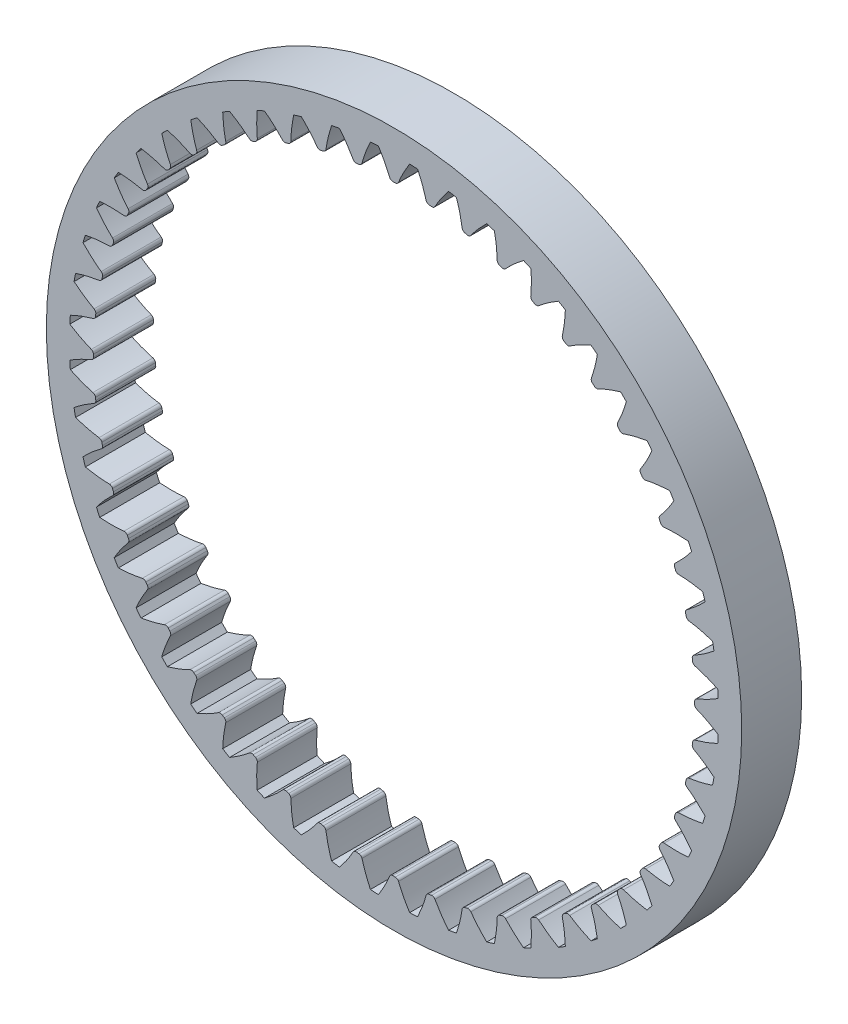
from build123d import *

# Parameters (mm, degrees)
SKETCH1_R               = 29
BOSS_EXTRUDE1_DEPTH     = 5
CUT_EXTRUDE1_DEPTH      = 6
CUT_EXTRUDE4_DEPTH      = 6.0000001
SKETCH3_R               = 25
CUT_EXTRUDE2_DEPTH      = 6.0000007
TOLERANCETOOTHCUT_DEPTH = 6.0000001
SKETCH8_R               = 25.07
TOLERANCEDID_DEPTH      = 6.0000001
CIRPATTERN1_COUNT       = 52


with BuildPart() as part:
    # Sketch1 → Boss-Extrude1 (new body)
    with BuildSketch(Plane.XY):
        Circle(SKETCH1_R)
    extrude(amount=BOSS_EXTRUDE1_DEPTH)

    # Sketch2 → Cut-Extrude1 (cut, through all)
    with BuildSketch(Plane.XY.offset(5)):
        with BuildLine():
            ThreePointArc((23.392853464, 2.834893097), (23.521011218, 1.422759062), (23.564001827, 0.005473364))
            add(Edge.make_bspline(
                [(23.564001827, 0.005473364), (23.569452708, 0.005539136), (23.584739427, 0.005923405), (23.613631002, 0.007438906), (23.660749085, 0.011032333), (23.720736108, 0.017257727), (23.798193272, 0.027194443), (23.889319268, 0.041330251), (23.989313256, 0.05940956), (24.097912346, 0.081822988), (24.206066118, 0.106608207), (24.313757985, 0.133587355), (24.420844889, 0.162495059), (24.550313362, 0.199910393), (24.705199064, 0.248107841), (24.885655098, 0.309290433), (25.089588699, 0.384394405), (25.296573432, 0.467032925), (25.49951497, 0.553352797), (25.703644763, 0.646303319), (25.900497494, 0.740300864), (26.103942442, 0.84378837), (26.291216414, 0.942291058), (26.499814884, 1.059103077), (26.667806924, 1.155257611), (26.840274008, 1.259949266), (26.924054804, 1.311694031), (26.966803552, 1.338471577)],
                knots=[0, 0, 0, 0, 0, 0.005376749, 0.015083688, 0.02853182, 0.04661014, 0.064854849, 0.092110526, 0.119476176, 0.146842496, 0.174208854, 0.201574956, 0.228941013, 0.256307345, 0.307035032, 0.361767352, 0.416499661, 0.471231937, 0.525964282, 0.580696616, 0.635428982, 0.690161387, 0.744893688, 0.799626082, 0.854358407, 0.909090914, 0.909090914, 0.909090914, 0.909090914, 0.909090914], degree=4))
            ThreePointArc((26.966803552, 1.338471577), (26.950739932, 1.630219428), (26.931520113, 1.921776365))
            add(Edge.make_bspline(
                [(23.392853464, 2.834893097), (23.39827253, 2.835484836), (23.41349411, 2.836945978), (23.442357707, 2.838924022), (23.489565386, 2.841036252), (23.549865424, 2.842086885), (23.627955576, 2.841559048), (23.720121044, 2.838510331), (23.821565183, 2.832615785), (23.932074104, 2.823455949), (24.042426842, 2.811887939), (24.15258549, 2.798086319), (24.262376049, 2.782297285), (24.395410472, 2.76076045), (24.554976443, 2.731583825), (24.741491496, 2.692598894), (24.952990974, 2.642623993), (25.168427529, 2.585537254), (25.380294105, 2.52430865), (25.59413951, 2.45664097), (25.800887114, 2.387056748), (26.01532276, 2.308846361), (26.213104481, 2.233635251), (26.434262166, 2.142818691), (26.612619504, 2.067614434), (26.796448293, 1.984474709), (26.885855375, 1.94320588), (26.931520113, 1.921776365)],
                knots=[0, 0, 0, 0, 0, 0.005376749, 0.015083688, 0.02853182, 0.04661014, 0.064854849, 0.092110526, 0.119476176, 0.146842496, 0.174208854, 0.201574956, 0.228941013, 0.256307345, 0.307035032, 0.361767352, 0.416499661, 0.471231937, 0.525964282, 0.580696616, 0.635428982, 0.690161387, 0.744893688, 0.799626082, 0.854358407, 0.909090914, 0.909090914, 0.909090914, 0.909090914, 0.909090914], degree=4))
        make_face()
    extrude(amount=-CUT_EXTRUDE1_DEPTH, mode=Mode.SUBTRACT)

    # Sketch5 → Cut-Extrude4 (cut, through all)
    with BuildSketch(Plane.XY.offset(5)):
        with BuildLine():
            Line((25.091558109, 2.605404787), (25.222659244, 0.438044664))
            ThreePointArc((25.222659244, 0.438044664), (25.060289868, 0.306558642), (24.999772798, 0.106583462))
            ThreePointArc((24.999772798, 0.106583462), (24.954388856, 1.509462436), (24.830343524, 2.907583272))
            ThreePointArc((24.830343524, 2.907583272), (24.914523701, 2.716360663), (25.091558109, 2.605404787))
        make_face()
    extrude(amount=-CUT_EXTRUDE4_DEPTH, mode=Mode.SUBTRACT)

    # Sketch3 → Cut-Extrude2 (cut, through all)
    with BuildSketch(Plane.XY.offset(5)):
        Circle(SKETCH3_R)
    extrude(amount=-CUT_EXTRUDE2_DEPTH, mode=Mode.SUBTRACT)

    # Sketch7 → ToleranceToothCut (cut, through all)
    with BuildSketch(Plane.XY.offset(5)):
        with BuildLine():
            ThreePointArc((24.899868486, 2.915724505), (25.024261144, 1.51368893), (25.069772162, 0.106881896))
            ThreePointArc((25.069772162, 0.106881896), (25.118378251, 0.267497922), (25.248790054, 0.37310484))
            add(Edge.make_bspline(
                [(27.038722282, 1.300921932), (26.974179666, 1.260492846), (26.908936657, 1.219980183), (26.793772456, 1.150205175), (26.714756133, 1.102772755), (26.643334443, 1.061099925), (26.538115612, 1.000543096), (26.465589104, 0.959675564), (26.314405679, 0.876234361), (26.240732064, 0.836785625), (26.09319084, 0.759926224), (26.017128282, 0.721150769), (25.865050101, 0.645972763), (25.789753884, 0.610003473), (25.560689891, 0.503706416), (25.405519661, 0.436170482), (25.248790054, 0.37310484)],
                knots=[0, 0, 0, 0, 0.125, 0.125, 0.1875, 0.25, 0.25, 0.375, 0.375, 0.5, 0.5, 0.625, 0.625, 0.75, 0.75, 1, 1, 1, 1], degree=3))
            ThreePointArc((27.038722282, 1.300921932), (27.02061222, 1.634445923), (26.998388365, 1.967721075))
            add(Edge.make_bspline(
                [(25.109670766, 2.673020848), (25.27285936, 2.629306692), (25.435038782, 2.580966875), (25.675245335, 2.503055457), (25.754328177, 2.476424379), (25.914359244, 2.420125505), (25.994541084, 2.390801095), (26.150270944, 2.332286215), (26.228162416, 2.302005478), (26.388301268, 2.237395803), (26.465225013, 2.205568346), (26.576975999, 2.158135773), (26.65290005, 2.125375718), (26.737057601, 2.087813499), (26.859792573, 2.03242874), (26.929443149, 2.000075636), (26.998388365, 1.967721075)],
                knots=[0, 0, 0, 0, 0.25, 0.25, 0.375, 0.375, 0.5, 0.5, 0.625, 0.625, 0.75, 0.75, 0.8125, 0.875, 0.875, 1, 1, 1, 1], degree=3))
            ThreePointArc((25.109670766, 2.673020848), (24.967480304, 2.762138367), (24.899868486, 2.915724505))
        make_face()
    tolerancetoothcut = extrude(amount=-TOLERANCETOOTHCUT_DEPTH, mode=Mode.SUBTRACT)

    # Sketch8 → TolerancedID (cut, through all)
    with BuildSketch(Plane.XY.offset(5)):
        Circle(SKETCH8_R)
    extrude(amount=-TOLERANCEDID_DEPTH, mode=Mode.SUBTRACT)

    # CirPattern1: ToleranceToothCut ×52 about axis
    cirpattern1_axis = Axis((0, 0, -0.261), (0, 0, 1))
    for i in range(1, CIRPATTERN1_COUNT):
        add(tolerancetoothcut.rotate(cirpattern1_axis, i * 360 / CIRPATTERN1_COUNT), mode=Mode.SUBTRACT)


solid = part.part
